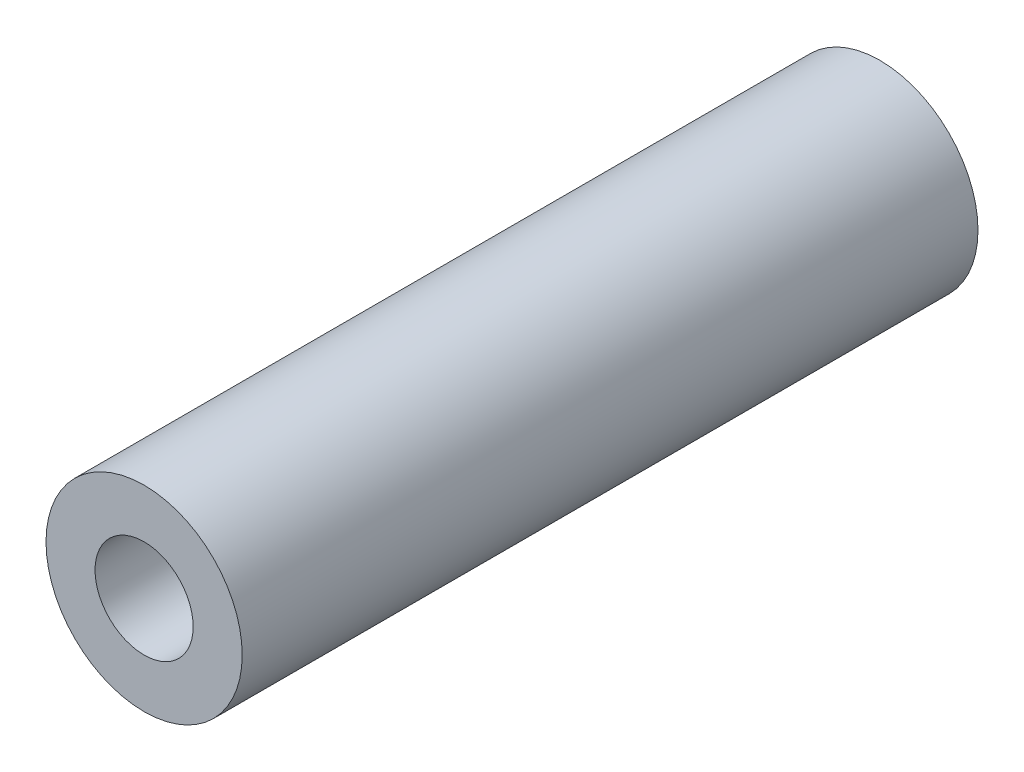
from build123d import *

# Parameters (mm, degrees)
SKETCH1_R           = 4
SKETCH1_R_2         = 2
BOSS_EXTRUDE1_DEPTH = 30


with BuildPart() as part:
    # Sketch1 → Boss-Extrude1 (new body)
    with BuildSketch(Plane.XY):
        Circle(SKETCH1_R)
        Circle(SKETCH1_R_2, mode=Mode.SUBTRACT)
    extrude(amount=BOSS_EXTRUDE1_DEPTH)


solid = part.part
